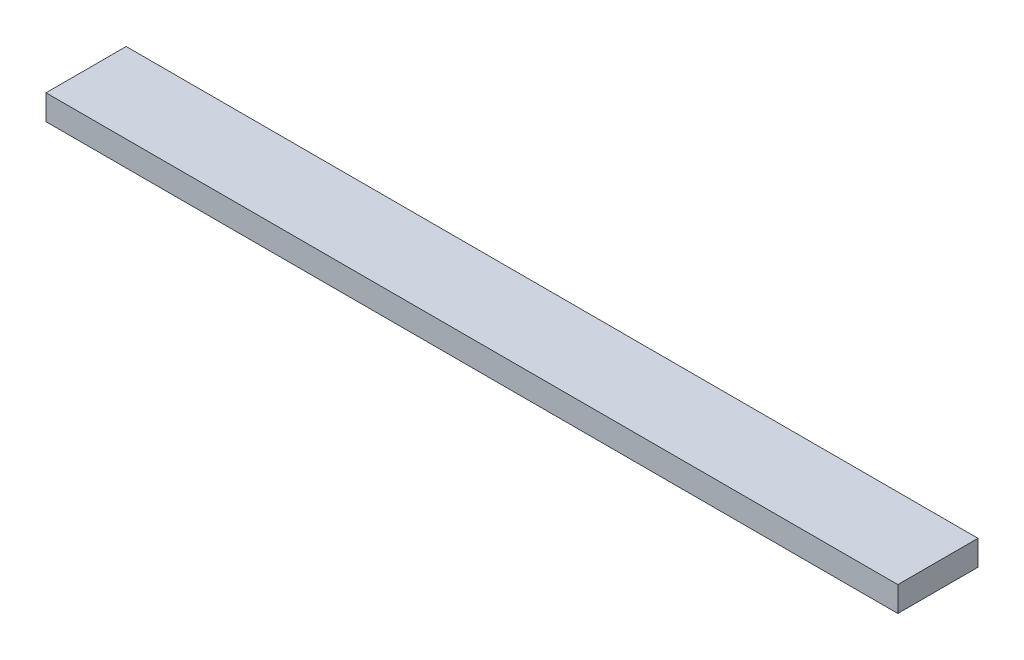
from build123d import *

# Parameters (mm, degrees)
SKETCH_1_W      = 80
SKETCH_1_H      = 25
EXTRUDE_1_DEPTH = 850


with BuildPart() as part:
    # Эскиз1 → Бобышка-Вытянуть1 (new body)
    with BuildSketch(Plane(origin=(0, 0, 0), x_dir=(0, 0, -1), z_dir=(1, 0, 0))):
        Rectangle(SKETCH_1_W, SKETCH_1_H)
    extrude(amount=EXTRUDE_1_DEPTH)


solid = part.part
